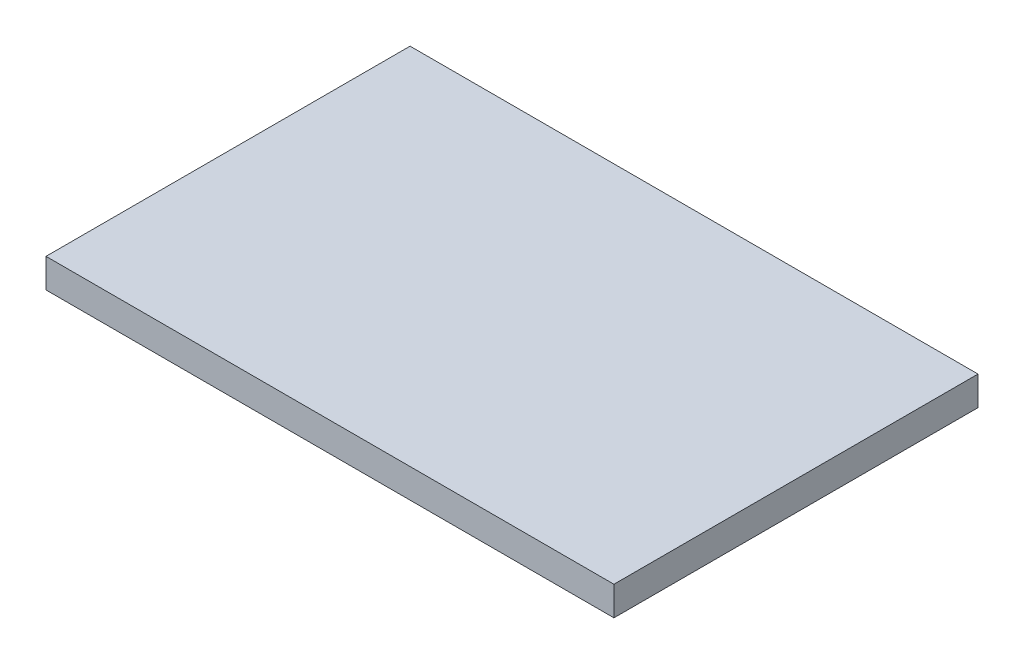
from build123d import *

# Parameters (mm, degrees)
SKETCH1_W           = 78
SKETCH1_H           = 50
BOSS_EXTRUDE1_DEPTH = 4


with BuildPart() as part:
    # Sketch1 → Boss-Extrude1 (new body)
    with BuildSketch(Plane(origin=(0, 0, 0), x_dir=(1, 0, 0), z_dir=(0, 1, 0))):
        Rectangle(SKETCH1_W, SKETCH1_H)
    extrude(amount=BOSS_EXTRUDE1_DEPTH)


solid = part.part
